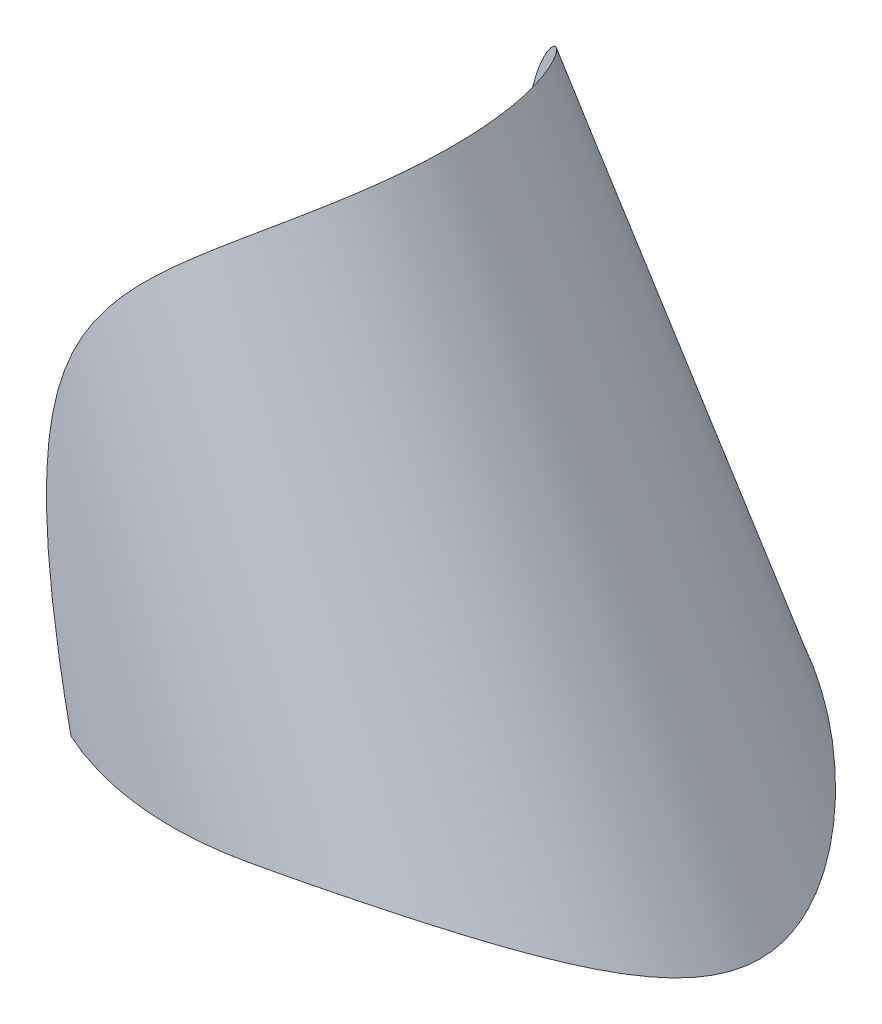
from build123d import *

# Parameters (mm, degrees)
ESQUISSE7_R                  = 16
ENL_V_MAT_EXTRU_4_DEPTH      = 31
ENL_V_MAT_EXTRU_4_DEPTH_BACK = 20.75582071
ENL_V_MAT_EXTRU_5_DEPTH      = 18.457623262
ENL_V_MAT_EXTRU_5_DEPTH_BACK = 18.457623262


with BuildPart() as part:
    # Esquisse6 → Révolution3 (revolve)
    with BuildSketch(Plane.XY, mode=Mode.PRIVATE) as r_volution3_sk:
        Polygon((30.254629316, 29.023433988), (49.837753266, -5.976566012), (51.58312395, -5), (32, 30), align=None)
    revolve(r_volution3_sk.sketch.rotate(Axis((16, 30, 0), (0.422618262, -0.906307787, 0)), 180), axis=Axis((16, 30, 0), (0.422618262, -0.906307787, 0)))  # turned: the seam where the file's is

    # Esquisse7 → Enlèv. mat.-Extru.4 (cut, two sides)
    with BuildSketch(Plane(origin=(0, 0, 0), x_dir=(1, 0, 0), z_dir=(0, 1, 0))) as enl_v_mat_extru_4_sk:
        with Locations((16, 0)):
            Circle(ESQUISSE7_R)
    extrude(amount=ENL_V_MAT_EXTRU_4_DEPTH, mode=Mode.SUBTRACT)
    extrude(enl_v_mat_extru_4_sk.sketch, amount=-ENL_V_MAT_EXTRU_4_DEPTH_BACK, mode=Mode.SUBTRACT)

    # Esquisse8 → Enlèv. mat.-Extru.5 (cut, two sides)
    with BuildSketch(Plane.XY) as enl_v_mat_extru_5_sk:
        with BuildLine():
            Line((0, 0), (35, 0))
            ThreePointArc((35, 0), (56.213203436, -8.786796564), (65, -30))
            Line((65, -30), (0, -30))
            Line((0, -30), (0, 0))
        make_face()
    extrude(amount=ENL_V_MAT_EXTRU_5_DEPTH, mode=Mode.SUBTRACT)
    extrude(enl_v_mat_extru_5_sk.sketch, amount=-ENL_V_MAT_EXTRU_5_DEPTH_BACK, mode=Mode.SUBTRACT)


solid = part.part
